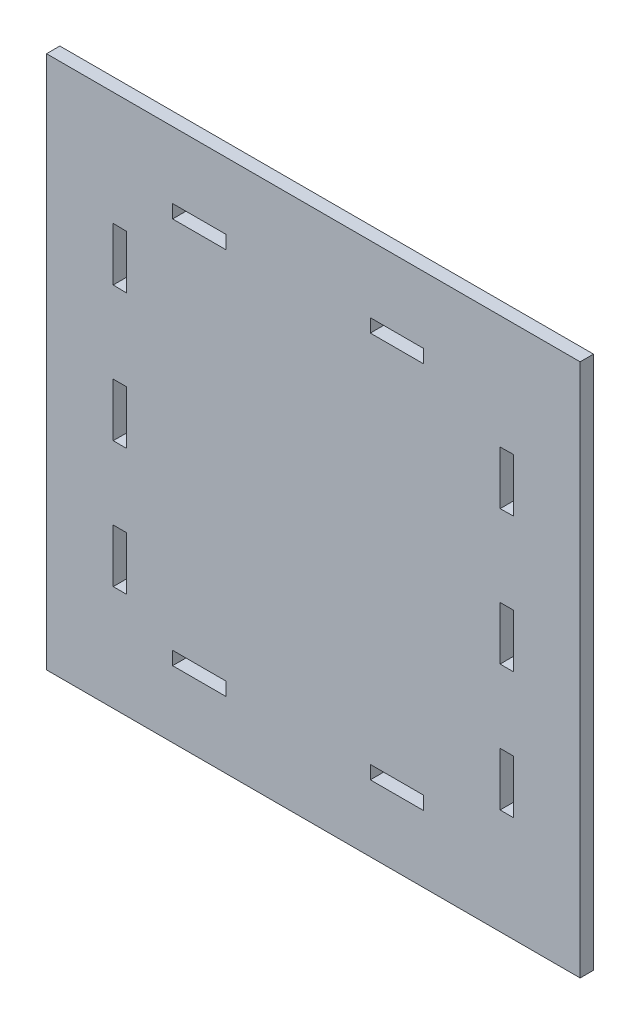
from build123d import *

# Parameters (mm, degrees)
SKETCH1_W           = 200
SKETCH1_H           = 200
SKETCH1_W_2         = 20
SKETCH1_H_2         = 5
SKETCH1_W_3         = 5
SKETCH1_H_3         = 20
BOSS_EXTRUDE1_DEPTH = 5


with BuildPart() as part:
    # Sketch1 → Boss-Extrude1 (new body)
    with BuildSketch(Plane.XY):
        Rectangle(SKETCH1_W, SKETCH1_H)
        with Locations((-42.738744268, 72.5)):
            Rectangle(SKETCH1_W_2, SKETCH1_H_2, mode=Mode.SUBTRACT)
        with Locations((31.360897281, 72.5)):
            Rectangle(SKETCH1_W_2, SKETCH1_H_2, mode=Mode.SUBTRACT)
        Polygon((-75, 57.435704121), (-70.001007164, 57.335351613), (-70.001007164, 37.335351613), (-75, 37.435704121), align=None, mode=Mode.SUBTRACT)
        with Locations((-72.5, -3.109084485)):
            Rectangle(SKETCH1_W_3, SKETCH1_H_3, mode=Mode.SUBTRACT)
        with Locations((-72.5, -50.464153422)):
            Rectangle(SKETCH1_W_3, SKETCH1_H_3, mode=Mode.SUBTRACT)
        with Locations((31.360897281, -72.5)):
            Rectangle(SKETCH1_W_2, SKETCH1_H_2, mode=Mode.SUBTRACT)
        with Locations((-42.738744268, -72.5)):
            Rectangle(SKETCH1_W_2, SKETCH1_H_2, mode=Mode.SUBTRACT)
        with Locations((72.5, -50.464153422)):
            Rectangle(SKETCH1_W_3, SKETCH1_H_3, mode=Mode.SUBTRACT)
        with Locations((72.5, -3.109084485)):
            Rectangle(SKETCH1_W_3, SKETCH1_H_3, mode=Mode.SUBTRACT)
        Polygon((75, 37.435704121), (70.001007164, 37.335351613), (70.001007164, 57.335351613), (75, 57.435704121), align=None, mode=Mode.SUBTRACT)
    extrude(amount=BOSS_EXTRUDE1_DEPTH)


solid = part.part
